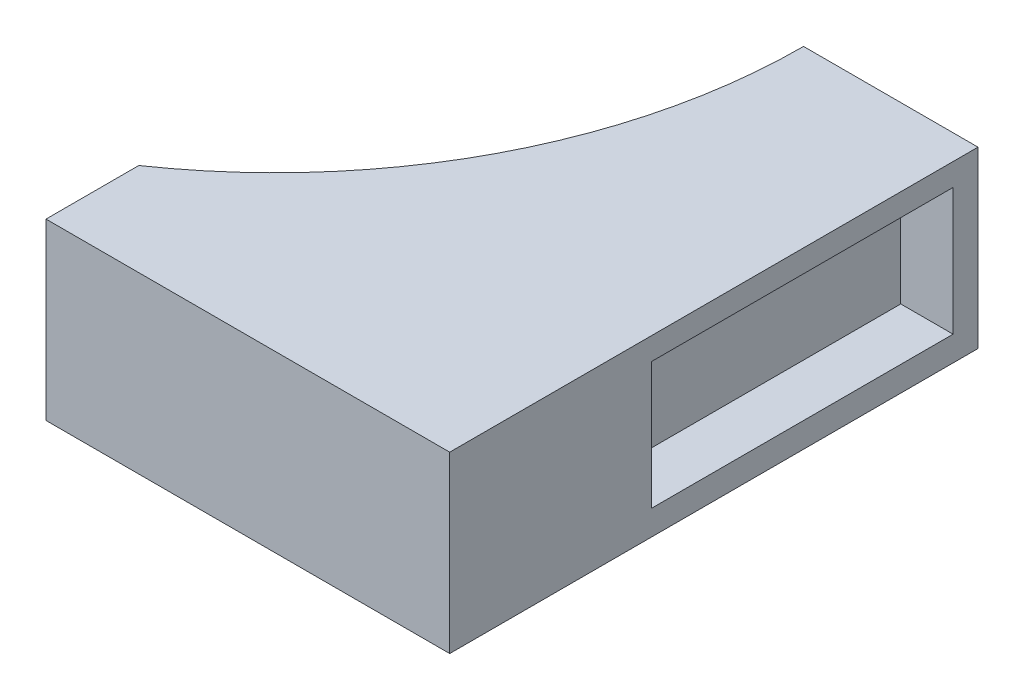
from build123d import *

# Parameters (mm, degrees)
BOSS_EXTRUDE1_DEPTH = 7
CUT_EXTRUDE1_DEPTH  = 8
SKETCH5_W           = 15
SKETCH5_H           = 3
CUT_EXTRUDE3_DEPTH  = 10
SKETCH6_W           = 12.1
SKETCH6_H           = 5.1
CUT_EXTRUDE4_DEPTH  = 2.1


with BuildPart() as part:
    # Sketch1 → Boss-Extrude1 (new body)
    with BuildSketch(Plane(origin=(0, 0, 0), x_dir=(1, 0, 0), z_dir=(0, 1, 0))):
        with BuildLine():
            Line((7, 21.2), (-21.2, 21.2))
            ThreePointArc((-21.2, 21.2), (-6.209336239, 14.990663761), (0, 0))
            Line((0, 0), (7, 0))
            Line((7, 0), (7, 21.2))
        make_face()
    extrude(amount=BOSS_EXTRUDE1_DEPTH)

    # Sketch2 → Cut-Extrude1 (cut, through all)
    with BuildSketch(Plane(origin=(0, 7, 0), x_dir=(1, 0, 0), z_dir=(0, 1, 0))):
        with BuildLine():
            Line((-9.2, 17.47684182), (-9.2, 21.2))
            Line((-9.2, 21.2), (-21.2, 21.2))
            ThreePointArc((-21.2, 21.2), (-14.917844581, 20.247827619), (-9.2, 17.47684182))
        make_face()
    extrude(amount=-CUT_EXTRUDE1_DEPTH, mode=Mode.SUBTRACT)

    # Sketch5 → Cut-Extrude3 (cut)
    with BuildSketch(Plane(origin=(0, 0, 0), x_dir=(0, 0, -1), z_dir=(1, 0, 0))):
        with Locations((9.5, 4.5)):
            Rectangle(SKETCH5_W, SKETCH5_H)
    extrude(amount=-CUT_EXTRUDE3_DEPTH, mode=Mode.SUBTRACT)

    # Sketch6 → Cut-Extrude4 (cut)
    with BuildSketch(Plane(origin=(7, 0, 0), x_dir=(0, 0, -1), z_dir=(1, 0, 0))):
        with Locations((7.05, 3.55)):
            Rectangle(SKETCH6_W, SKETCH6_H)
    extrude(amount=-CUT_EXTRUDE4_DEPTH, mode=Mode.SUBTRACT)


with BuildPart() as body_2:
    # Mirror1: mirrored copy
    add(part.part.mirror(Plane(origin=(0, 7, 0), x_dir=(1, 0, 0), z_dir=(0, 0, -1))))


solid = body_2.part
